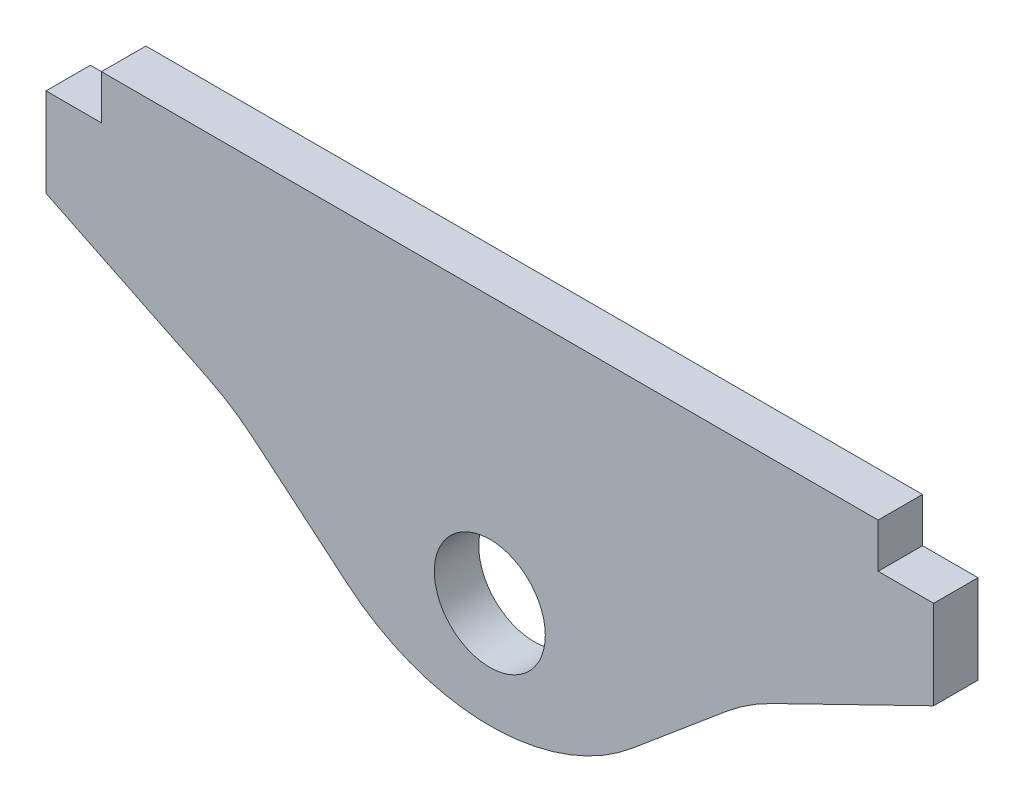
from build123d import *

# Parameters (mm, degrees)
SKETCH_1_R      = 2.5
EXTRUDE_1_DEPTH = 2
FILLET_1_R      = 10


with BuildPart() as part:
    # ｽｹｯﾁ1 → ﾎﾞｽ - 押し出し1 (new body)
    with BuildSketch(Plane.XY):
        Polygon((0, -7.832443736), (11.605504985, 1.905731217), (20, 6), (20, 10), (17.5, 10), (17.5, 12), (-17.5, 12), (-17.5, 10), (-20, 10), (-20, 6), (-11.605504985, 1.905731217), align=None)
        Circle(SKETCH_1_R, mode=Mode.SUBTRACT)
    extrude(amount=EXTRUDE_1_DEPTH)

    # ﾌｨﾚｯﾄ1
    fillet_1_edges = [part.edges().sort_by_distance(p)[0] for p in [
        (11.605504985, 1.905731217, 1),
        (0, -7.832443736, 1),
        (-11.605504985, 1.905731217, 1),
    ]]
    fillet(fillet_1_edges, radius=FILLET_1_R)


solid = part.part
